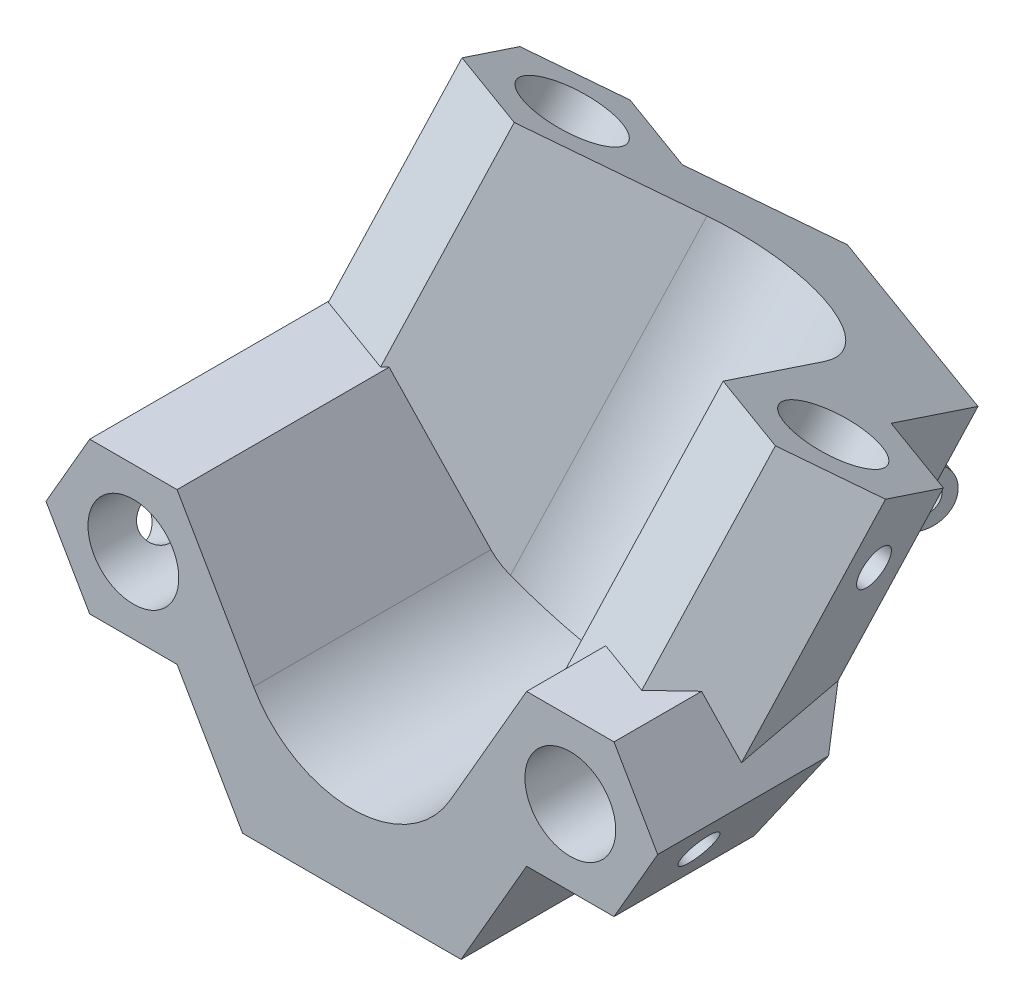
from build123d import *
from build123d.topology import SkipClean

# Parameters (mm, degrees)
SKETCH5_R                      = 3.6
BOSS_EXTRUDE2_DEPTH            = 15
BOSS_EXTRUDE3_REACH            = 51.045
SKETCH6_R                      = 3.5
SKETCH6_R_2                    = 3.6
SKETCH7_R                      = 3.6
SKETCH7_R_2                    = 9
CUT_EXTRUDE1_DEPTH             = 15
SKETCH8_W                      = 48.497422612
SKETCH8_H                      = 6.75711345
CUT_EXTRUDE2_DEPTH             = 42.269694796
CUT_EXTRUDE2_DEPTH_BACK        = 42.269694796
CUT_EXTRUDE3_DEPTH             = 52.625225339
CUT_EXTRUDE3_DEPTH_BACK        = 52.625225339
BOSS_EXTRUDE4_REACH            = 43.27
CUT_EXTRUDE4_DEPTH             = 50.044816115
CUT_EXTRUDE4_DEPTH_BACK        = 50.044816115
CUT_EXTRUDE5_REACH             = 61.364
CUT_EXTRUDE5_END_RADIUS        = 3.6
SKETCH12_R                     = 1.5
CUT_EXTRUDE5_DIRECTION_2_DEPTH = 60.36438735
CUT_EXTRUDE6_REACH             = 59.915
CUT_EXTRUDE6_END_RADIUS        = 3.6
SKETCH13_R                     = 1.5
CUT_EXTRUDE7_REACH             = 57.894
CUT_EXTRUDE7_END_RADIUS        = 3.5
SKETCH14_R                     = 1.5
CUT_EXTRUDE8_REACH             = 58.167
CUT_EXTRUDE8_END_RADIUS        = 3.6
SKETCH15_R                     = 1.5
BOSS_EXTRUDE5_DEPTH            = 7
SKETCH17_R                     = 1.25
CUT_EXTRUDE9_DEPTH             = 43.79253318
CUT_EXTRUDE10_REACH            = 44.793


with BuildPart() as part:
    # Sketch5 → Boss-Extrude2 (new body)
    with BuildSketch(Plane.XY):
        with BuildLine():
            Line((-13.856406461, -6), (-8.660254038, -15))
            Line((-8.660254038, -15), (8.660254038, -15))
            Line((8.660254038, -15), (13.856406461, -6))
            Line((13.856406461, -6), (20.784609691, -6))
            Line((20.784609691, -6), (24.248711306, 0))
            Line((24.248711306, 0), (20.784609691, 6))
            Line((20.784609691, 6), (13.856406461, 6))
            Line((13.856406461, 6), (7.794228634, -4.5))
            ThreePointArc((7.794228634, -4.5), (0, -9), (-7.794228634, -4.5))
            Line((-7.794228634, -4.5), (-13.856406461, 6))
            Line((-13.856406461, 6), (-20.784609691, 6))
            Line((-20.784609691, 6), (-24.248711306, 0))
            Line((-24.248711306, 0), (-20.784609691, -6))
            Line((-20.784609691, -6), (-13.856406461, -6))
        make_face()
        with Locations((17.320508076, 0)):
            Circle(SKETCH5_R, mode=Mode.SUBTRACT)
        with Locations(Location((-17.320508076, 0, 0), (0, 0, 180))):
            Circle(SKETCH5_R, mode=Mode.SUBTRACT)
    extrude(amount=BOSS_EXTRUDE2_DEPTH)

    # Boss-Extrude3: up to this face of the body (flat: up to its plane)
    boss_extrude3_end = Plane(part.part.faces().sort_by_distance((0, -15, 7.5))[0])
    # Sketch6 → Boss-Extrude3 (add, up to the picked face)
    with BuildSketch(Plane(origin=(3.420201433, 17.320508076, -9.396926208), x_dir=(0.9852692806486326, -0.15031328924160728, 0.08154973750721087), z_dir=(0.1710100716628295, 0.8660254037844416, -0.46984631039295055)), mode=Mode.PRIVATE) as boss_extrude3_sk1:
        with BuildLine():
            Line((-3.750248683, 16.909631422), (-11.411676306, 9.888055617))
            Line((-11.411676306, 9.888055617), (-18.019394195, 11.970857649))
            Line((-18.019394195, 11.970857649), (-23.12701261, 7.289807113))
            Line((-23.12701261, 7.289807113), (-21.626913137, 0.525954544))
            Line((-21.626913137, 0.525954544), (-15.019195248, -1.556847488))
            Line((-15.019195248, -1.556847488), (-6.080863021, 6.634990951))
            ThreePointArc((-6.080863021, 6.634990951), (2.705639206, 8.583677329), (8.786502228, 1.948686378))
            Line((8.786502228, 1.948686378), (11.411676306, -9.888055617))
            Line((11.411676306, -9.888055617), (18.019394195, -11.970857649))
            Line((18.019394195, -11.970857649), (23.12701261, -7.289807113))
            Line((23.12701261, -7.289807113), (21.626913137, -0.525954544))
            Line((21.626913137, -0.525954544), (15.019195248, 1.556847488))
            Line((15.019195248, 1.556847488), (12.769046038, 11.702626341))
            Line((12.769046038, 11.702626341), (-3.750248683, 16.909631422))
        make_face()
        with Locations(Location((16.519294721, -5.20700508, 0), (0, 0, 255.051444771))):
            Circle(SKETCH6_R, mode=Mode.SUBTRACT)
        with Locations(Location((-16.519294721, 5.20700508, 0), (0, 0, 270))):
            Circle(SKETCH6_R_2, mode=Mode.SUBTRACT)
    boss_extrude3_tool1 = split(extrude(boss_extrude3_sk1.sketch, amount=-BOSS_EXTRUDE3_REACH, mode=Mode.PRIVATE), bisect_by=boss_extrude3_end, keep=Keep.BOTH, mode=Mode.PRIVATE)
    add(boss_extrude3_tool1.solids().sort_by(Axis((-3.686083, 12.206833, -21.408979), (-0.1710100716628295, -0.8660254037844416, 0.46984631039295055)))[0])

    # Sketch7 → Cut-Extrude1 (cut)
    with BuildSketch(Plane.XY.offset(15)):
        with Locations(Location((-17.320508076, 0, 0), (0, 0, 180))):
            Circle(SKETCH7_R)
        Circle(SKETCH7_R_2)
        with Locations(Location((17.320508076, 0, 0), (0, 0, 235.205682737))):
            Circle(SKETCH7_R)
    extrude(amount=-CUT_EXTRUDE1_DEPTH, mode=Mode.SUBTRACT)

    # Sketch8 → Cut-Extrude2 (cut, two sides)
    with BuildSketch(Plane(origin=(0, 0, 0), x_dir=(1, 0, 0), z_dir=(0, 1, 0))) as cut_extrude2_sk:
        with Locations((0, -18.378556725)):
            Rectangle(SKETCH8_W, SKETCH8_H)
    extrude(amount=CUT_EXTRUDE2_DEPTH, mode=Mode.SUBTRACT)
    extrude(cut_extrude2_sk.sketch, amount=-CUT_EXTRUDE2_DEPTH_BACK, mode=Mode.SUBTRACT)

    # Sketch9 → Cut-Extrude3 (cut, two sides)
    with BuildSketch(Plane.XY.offset(15)) as cut_extrude3_sk:
        Polygon((-8.660254038, -15), (-13.856406461, -6), (-20.784609691, -6), (-24.248711306, 0), (-25.748316405, -15), align=None)
        Polygon((8.660254038, -15), (13.856406461, -6), (20.784609691, -6), (24.248711306, 0), (19.659605529, -15), align=None)
    extrude(amount=CUT_EXTRUDE3_DEPTH, mode=Mode.SUBTRACT)
    extrude(cut_extrude3_sk.sketch, amount=-CUT_EXTRUDE3_DEPTH_BACK, mode=Mode.SUBTRACT)

    # Boss-Extrude4: up to this face of the body (flat: up to its plane)
    boss_extrude4_end = Plane(part.part.faces().sort_by_distance((5.307826124, -2.386655305, -15.033840033))[0])
    # Sketch10 → Boss-Extrude4 (add, up to the picked face)
    with BuildSketch(Plane(origin=(0, 0, 0), x_dir=(-1, 0, 0), z_dir=(0, 0, -1)), mode=Mode.PRIVATE) as boss_extrude4_sk1:
        with BuildLine():
            Line((-7.794228634, -4.5), (-13.856406461, 6))
            Line((-13.856406461, 6), (-20.784609691, 6))
            Line((-20.784609691, 6), (-24.248711306, 0))
            Line((-24.248711306, 0), (-20.784609691, -6))
            Line((-20.784609691, -6), (-13.856406461, -6))
            Line((-13.856406461, -6), (-8.660254038, -15))
            Line((-8.660254038, -15), (8.660254038, -15))
            Line((8.660254038, -15), (13.856406461, -6))
            Line((13.856406461, -6), (20.784609691, -6))
            Line((20.784609691, -6), (24.248711306, 0))
            Line((24.248711306, 0), (20.784609691, 6))
            Line((20.784609691, 6), (13.856406461, 6))
            Line((13.856406461, 6), (7.794228634, -4.5))
            ThreePointArc((7.794228634, -4.5), (0, -9), (-7.794228634, -4.5))
        make_face()
    boss_extrude4_tool1 = split(extrude(boss_extrude4_sk1.sketch, amount=BOSS_EXTRUDE4_REACH, mode=Mode.PRIVATE), bisect_by=boss_extrude4_end, keep=Keep.BOTH, mode=Mode.PRIVATE)
    add(boss_extrude4_tool1.solids().sort_by(Axis((11.283002, 0.485756, 0), (0, 0, -1)))[0])

    # Sketch11 → Cut-Extrude4 (cut, two sides)
    with SkipClean():  # the faces are left unmerged after this step: merging them gives an invalid solid
        with BuildSketch(Plane(origin=(3.420201433, 17.320508076, -9.396926208), x_dir=(0.9852692806486326, -0.15031328924160733, 0.08154973750721092), z_dir=(0.17101007166282958, 0.8660254037844416, -0.4698463103929507))) as cut_extrude4_sk:
            Polygon((-3.750248683, 16.909631422), (-11.411676306, 9.888055617), (-18.019394195, 11.970857649), (-24.454933942, 6.072788464), (-26.114385656, 23.958974435), align=None)
            Polygon((12.769046038, 11.702626341), (15.019195248, 1.556847488), (24.009999606, -1.277121199), (23.108119871, 8.443673045), align=None)
        extrude(amount=CUT_EXTRUDE4_DEPTH, mode=Mode.SUBTRACT)
        extrude(cut_extrude4_sk.sketch, amount=-CUT_EXTRUDE4_DEPTH_BACK, mode=Mode.SUBTRACT)

    # Cut-Extrude5: up to this cylinder (the profile starts outside it)
    with SkipClean():  # the faces are left unmerged after this step: merging them gives an invalid solid
        cut_extrude5_end = Plane(origin=(-17.320508076, 0, 10), z_dir=(0, 0, -1)) * Cylinder(CUT_EXTRUDE5_END_RADIUS, 130.928, mode=Mode.PRIVATE)
        # Sketch12 → Cut-Extrude5 (cut, up to the surface)
        with BuildSketch(Plane(origin=(-18.186533479, -10.5, 0), x_dir=(0, 0, 1), z_dir=(-0.8660254037844402, -0.4999999999999974, 0)), mode=Mode.PRIVATE) as cut_extrude5_sk1:
            with Locations(Location((10, 8.660254038, 0), (0, 0, 270))):
                Circle(SKETCH12_R)
        cut_extrude5_tool1 = extrude(cut_extrude5_sk1.sketch, amount=-CUT_EXTRUDE5_REACH, mode=Mode.PRIVATE) - cut_extrude5_end
        add(cut_extrude5_tool1.solids().sort_by_distance((-22.51666, -3, 10))[0], mode=Mode.SUBTRACT)

    # Sketch12 → Cut-Extrude5 direction 2 (cut)
    with SkipClean():  # the faces are left unmerged after this step: merging them gives an invalid solid
        with BuildSketch(Plane(origin=(-18.186533479, -10.5, 0), x_dir=(0, 0, 1), z_dir=(-0.8660254037844402, -0.4999999999999974, 0))):
            with Locations(Location((10, 8.660254038, 0), (0, 0, 270))):
                Circle(SKETCH12_R)
        extrude(amount=CUT_EXTRUDE5_DIRECTION_2_DEPTH, mode=Mode.SUBTRACT)

    # Cut-Extrude6: up to this cylinder (the profile starts outside it)
    with SkipClean():  # the faces are left unmerged after this step: merging them gives an invalid solid
        cut_extrude6_end = Plane(origin=(17.320508076, 0, 10), z_dir=(0, 0, -1)) * Cylinder(CUT_EXTRUDE6_END_RADIUS, 128.03, mode=Mode.PRIVATE)
        # Sketch13 → Cut-Extrude6 (cut, up to the surface)
        with BuildSketch(Plane(origin=(18.186533479, -10.5, 0), x_dir=(0, 0, -1), z_dir=(0.8660254037844402, -0.4999999999999974, 0)), mode=Mode.PRIVATE) as cut_extrude6_sk1:
            with Locations(Location((-10, 8.660254038, 0), (0, 0, 90))):
                Circle(SKETCH13_R)
        cut_extrude6_tool1 = extrude(cut_extrude6_sk1.sketch, amount=-CUT_EXTRUDE6_REACH, mode=Mode.PRIVATE) - cut_extrude6_end
        add(cut_extrude6_tool1.solids().sort_by_distance((22.51666, -3, 10))[0], mode=Mode.SUBTRACT)

    # Cut-Extrude7: up to this cylinder (the profile starts outside it)
    with SkipClean():  # the faces are left unmerged after this step: merging them gives an invalid solid
        cut_extrude7_end = Plane(origin=(18.841104668, 12.990380885, -1.123731908), z_dir=(0.1710100716628295, 0.8660254037844416, -0.46984631039295055)) * Cylinder(CUT_EXTRUDE7_END_RADIUS, 123.788, mode=Mode.PRIVATE)
        # Sketch14 → Cut-Extrude7 (cut, up to the surface)
        with BuildSketch(Plane(origin=(20.199831702, -5.25, -2.324714867), x_dir=(-0.10714116317598488, 0.027846326393864564, -0.9938537886729936), z_dir=(0.9618967477123858, -0.2499999999999971, -0.1107007079486697)), mode=Mode.PRIVATE) as cut_extrude7_sk1:
            with Locations(Location((-0.540098175, 17.3120852, 0), (0, 0, 90))):
                Circle(SKETCH14_R)
        cut_extrude7_tool1 = extrude(cut_extrude7_sk1.sketch, amount=-CUT_EXTRUDE7_REACH, mode=Mode.PRIVATE) - cut_extrude7_end
        add(cut_extrude7_tool1.solids().sort_by_distance((24.612485, 11.490381, -1.787936))[0], mode=Mode.SUBTRACT)

    # Cut-Extrude8: up to this cylinder (the profile starts outside it)
    with SkipClean():  # the faces are left unmerged after this step: merging them gives an invalid solid
        cut_extrude8_end = Plane(origin=(-13.710802565, 12.990380989, -12.971657273), z_dir=(0.1710100716628295, 0.8660254037844416, -0.46984631039295055)) * Cylinder(CUT_EXTRUDE8_END_RADIUS, 124.534, mode=Mode.PRIVATE)
        # Sketch15 → Cut-Extrude8 (cut, up to the surface)
        with BuildSketch(Plane(origin=(-13.979670915, -5.25, -14.765036441), x_dir=(-0.7462207140017174, 0.22302336376340076, 0.6272282082387757), z_dir=(-0.6656986149863668, -0.24999999999999695, -0.703096973400707)), mode=Mode.PRIVATE) as cut_extrude8_sk1:
            with Locations(Location((4.992253977, 16.585457492, 0), (0, 0, 346.683055075))):
                Circle(SKETCH15_R)
        cut_extrude8_tool1 = extrude(cut_extrude8_sk1.sketch, amount=-CUT_EXTRUDE8_REACH, mode=Mode.PRIVATE) - cut_extrude8_end
        add(cut_extrude8_tool1.solids().sort_by_distance((-17.704994, 11.490381, -17.190239))[0], mode=Mode.SUBTRACT)

    # Sketch16 → Boss-Extrude5 (add)
    with SkipClean():  # the faces are left unmerged after this step: merging them gives an invalid solid
        with BuildSketch(Plane(origin=(4.442971991, -7.5, -12.20696522), x_dir=(-0.9551265184097965, -0.15505701444619138, -0.25237007766653785), z_dir=(0.2961981327260197, -0.49999999999999495, -0.8137976813493785))):
            Polygon((-3.712913405, 6.439275895), (-5.145268749, 14.310003826), (-0.226063792, 15.205225916), (1.206291552, 7.334497985), align=None)
        extrude(amount=BOSS_EXTRUDE5_DEPTH)

    # Sketch17 → Cut-Extrude9 (cut, through all)
    with SkipClean():  # the faces are left unmerged after this step: merging them gives an invalid solid
        with BuildSketch(Plane(origin=(2.349231552, 0, 0.855050358), x_dir=(0.3420201433256625, 0, -0.9396926207859106), z_dir=(0.9396926207859108, 0, 0.34202014332566255))):
            with Locations((22.387495374, -0.223720558)):
                Circle(SKETCH17_R)
        extrude(amount=-CUT_EXTRUDE9_DEPTH, mode=Mode.SUBTRACT)

    # Sketch18 → Cut-Extrude10 (cut, up to next)
    with BuildSketch(Plane(origin=(2.349231552, 0, 0.855050358), x_dir=(0.3420201433256622, 0, -0.9396926207859108), z_dir=(0.9396926207859108, 0, 0.3420201433256622)), mode=Mode.PRIVATE) as cut_extrude10_sk1:
        with BuildLine():
            Line((20.490381057, 5.490381057), (23.512495374, 1.7248366))
            ThreePointArc((23.512495374, 1.7248366), (24.336052532, -1.348720558), (21.262495374, -2.172277717))
            Line((21.262495374, -2.172277717), (16.490381057, -1.437822174))
            Line((16.490381057, -1.437822174), (22.552558883, -4.937822174))
            Line((22.552558883, -4.937822174), (26.552558883, 1.990381057))
            Line((26.552558883, 1.990381057), (20.490381057, 5.490381057))
        make_face()
    cut_extrude10_tool1 = extrude(cut_extrude10_sk1.sketch, amount=-CUT_EXTRUDE10_REACH, mode=Mode.PRIVATE) & part.part
    add(cut_extrude10_tool1.solids().sort_by_distance((9.91282, 3.698312, -19.925739))[0], mode=Mode.SUBTRACT)


solid = part.part
